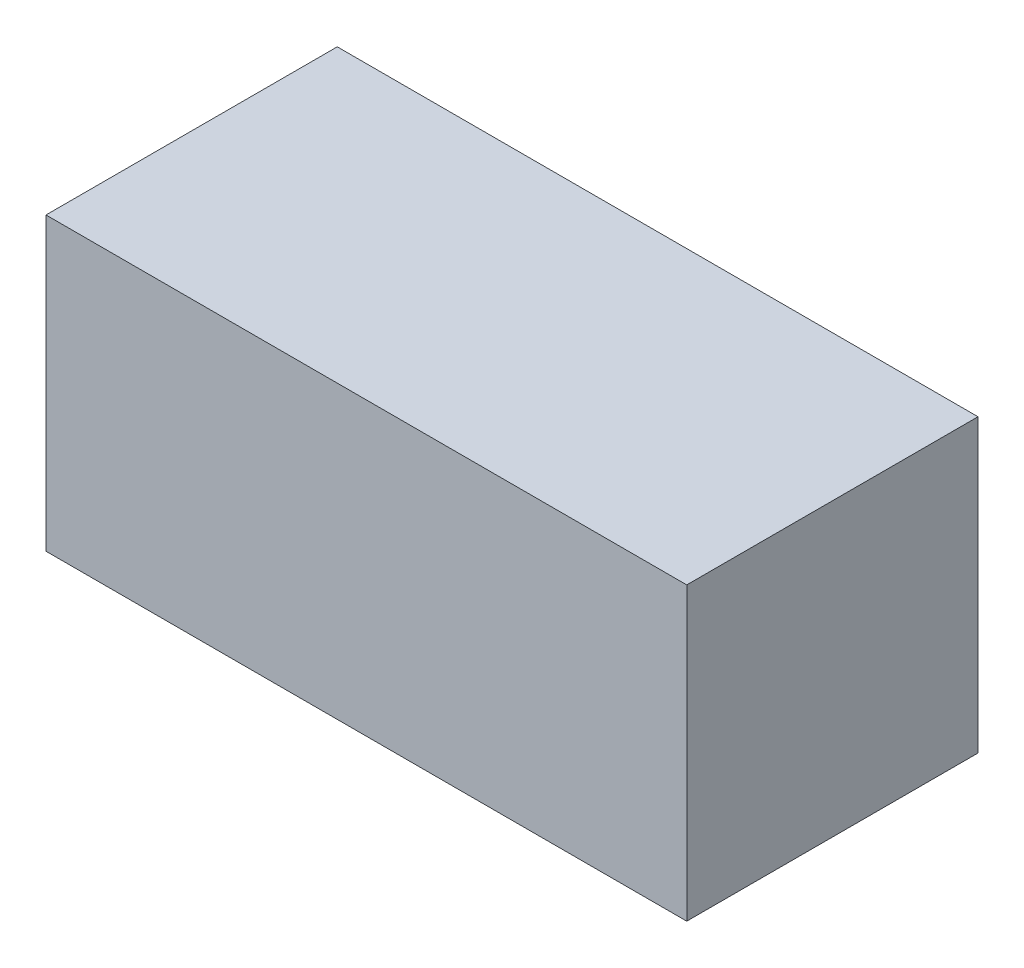
from build123d import *

# Parameters (mm, degrees)
SKETCH1_W           = 167.64
SKETCH1_H           = 76.2
BOSS_EXTRUDE1_DEPTH = 76.2


with BuildPart() as part:
    # Sketch1 → Boss-Extrude1 (new body)
    with BuildSketch(Plane.XY):
        Rectangle(SKETCH1_W, SKETCH1_H)
    extrude(amount=BOSS_EXTRUDE1_DEPTH)


solid = part.part
